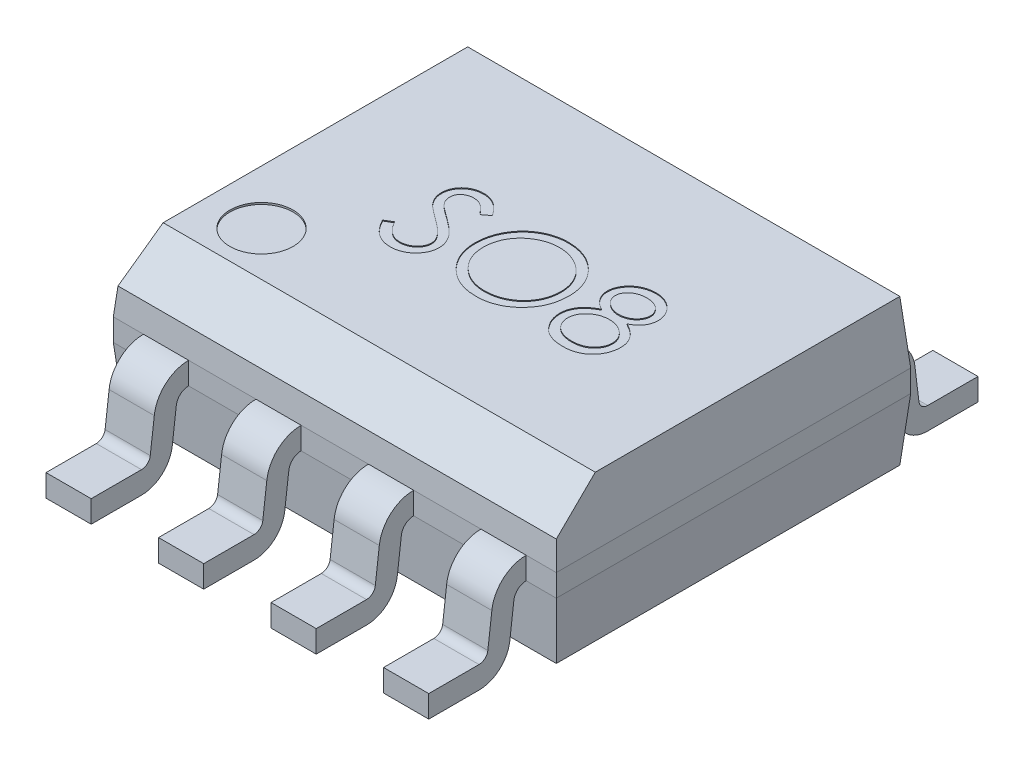
from build123d import *

# Parameters (mm, degrees)
SKETCH1_W                = 5
SKETCH1_H                = 4
BOSS_EXTRUDE1_DEPTH      = 0.125
BOSS_EXTRUDE1_DEPTH_BACK = 0.125
SKETCH2_W                = 5
SKETCH2_H                = 4
BOSS_EXTRUDE2_DEPTH      = 0.7
BOSS_EXTRUDE2_TAPER      = 5
SKETCH3_W                = 5
SKETCH3_H                = 4
BOSS_EXTRUDE3_DEPTH      = 0.7
BOSS_EXTRUDE3_TAPER      = 5
CHAMFER1_SIZE            = 0.4
CHAMFER1_SIZE2           = 0.440025147
BOSS_EXTRUDE4_START      = 0.38
BOSS_EXTRUDE4_DEPTH      = 0.51
LPATTERN1_COUNT          = 2
LPATTERN1_PITCH          = 1.27
LPATTERN1_COL_COUNT      = 3
LPATTERN1_COL_PITCH      = 1.27
SKETCH6_R                = 0.356697025
CUT_EXTRUDE1_DEPTH       = 0.02
CUT_EXTRUDE2_DEPTH       = 0.01


with BuildPart() as part:
    # Sketch1 → Boss-Extrude1 (new, two sides)
    with BuildSketch(Plane(origin=(0, 0.92, 0), x_dir=(1, 0, 0), z_dir=(0, 1, 0))) as boss_extrude1_sk:
        Rectangle(SKETCH1_W, SKETCH1_H)
    extrude(amount=BOSS_EXTRUDE1_DEPTH)
    extrude(boss_extrude1_sk.sketch, amount=-BOSS_EXTRUDE1_DEPTH_BACK)

    # Sketch2 → Boss-Extrude2 (add)
    with BuildSketch(Plane(origin=(0, 1.045, 0), x_dir=(1, 0, 0), z_dir=(0, 1, 0))):
        Rectangle(SKETCH2_W, SKETCH2_H)
    extrude(amount=BOSS_EXTRUDE2_DEPTH, taper=BOSS_EXTRUDE2_TAPER)

    # Sketch3 → Boss-Extrude3 (add)
    with BuildSketch(Plane.XZ.offset(-0.795)):
        Rectangle(SKETCH3_W, SKETCH3_H)
    extrude(amount=BOSS_EXTRUDE3_DEPTH, taper=BOSS_EXTRUDE3_TAPER)

    # Chamfer1
    chamfer1_edges = [part.edges().sort_by_distance(p)[0] for p in [
        (0, 1.745, 1.938757936),
    ]]
    chamfer1_side = [part.faces().sort_by_distance(p)[0] for p in [
        (0, 1.393553299, 1.969505538),
    ]]
    chamfer(chamfer1_edges, length=CHAMFER1_SIZE, length2=CHAMFER1_SIZE2, reference=chamfer1_side[0])

    # Sketch5 → Boss-Extrude4 (add)
    with BuildSketch(Plane(origin=(0, 0, 0), x_dir=(0, 0, -1), z_dir=(1, 0, 0)).offset(BOSS_EXTRUDE4_START)):
        with BuildLine():
            Line((2.43285762, 0.329963507), (2.38761047, 0.698105953))
            ThreePointArc((2.38761047, 0.698105953), (2.260085254, 0.945612561), (2, 1.045))
            Line((2, 1.045), (2, 0.795))
            ThreePointArc((2, 0.795), (2.091746463, 0.76074775), (2.138599743, 0.674751237))
            Line((2.138599743, 0.674751237), (2.184724748, 0.299466331))
            ThreePointArc((2.184724748, 0.299466331), (2.300209515, 0.080013931), (2.532110769, -0.007837622))
            Line((2.532110769, -0.007837622), (3.099630301, -0.007837622))
            Line((3.099630301, -0.007837622), (3.099630301, 0.242162378))
            Line((3.099630301, 0.242162378), (2.532110769, 0.242162378))
            ThreePointArc((2.532110769, 0.242162378), (2.465853268, 0.267262822), (2.43285762, 0.329963507))
        make_face()
        with BuildLine():
            ThreePointArc((-2.138599743, 0.674751237), (-2.091746463, 0.76074775), (-2, 0.795))
            Line((-2, 0.795), (-2, 1.045))
            ThreePointArc((-2, 1.045), (-2.260085254, 0.945612561), (-2.38761047, 0.698105953))
            Line((-2.38761047, 0.698105953), (-2.43285762, 0.329963507))
            ThreePointArc((-2.43285762, 0.329963507), (-2.465853268, 0.267262822), (-2.532110769, 0.242162378))
            Line((-2.532110769, 0.242162378), (-3.099630301, 0.242162378))
            Line((-3.099630301, 0.242162378), (-3.099630301, -0.007837622))
            Line((-3.099630301, -0.007837622), (-2.532110769, -0.007837622))
            ThreePointArc((-2.532110769, -0.007837622), (-2.300209515, 0.080013931), (-2.184724748, 0.299466331))
            Line((-2.184724748, 0.299466331), (-2.138599743, 0.674751237))
        make_face()
    boss_extrude4 = extrude(amount=BOSS_EXTRUDE4_DEPTH)

    # LPattern1: Boss-Extrude4 ×2
    with Locations(*[(i * LPATTERN1_PITCH, 0, 0) for i in range(1, LPATTERN1_COUNT)]):
        add(boss_extrude4)

    # LPattern1 col: Boss-Extrude4 ×3
    with Locations(*[(-i * LPATTERN1_COL_PITCH, 0, 0) for i in range(1, LPATTERN1_COL_COUNT)]):
        add(boss_extrude4)

    # Sketch6 → Cut-Extrude1 (cut)
    with BuildSketch(Plane(origin=(0, 1.745, 0), x_dir=(1, 0, 0), z_dir=(0, 1, 0))):
        with Locations(Location((-1.829466097, -0.997890598, 0), (0, 0, 270))):
            Circle(SKETCH6_R)
    extrude(amount=-CUT_EXTRUDE1_DEPTH, mode=Mode.SUBTRACT)

    # Sketch7 → Cut-Extrude2 (cut)
    with BuildSketch(Plane(origin=(0, 1.745, 0), x_dir=(1, 0, 0), z_dir=(0, 1, 0))):
        with BuildLine():
            Line((-1.226287299, -0.23455359), (-1.141752043, -0.1838725))
            add(Edge.make_bspline(
                [(-1.141752043, -0.1838725), (-1.133889689, -0.197033753), (-1.118825723, -0.222250206), (-1.093696763, -0.256323932), (-1.067658789, -0.285284548), (-1.040518979, -0.308963579), (-1.012442994, -0.327606118), (-0.98324755, -0.340806755), (-0.953031033, -0.349039891), (-0.932467084, -0.350039916), (-0.92220076, -0.350539167)],
                knots=[0, 0, 0, 0, 1.272034388, 2.437168799, 3.508375237, 4.49857839, 5.41946034, 6.295179144, 7.148887113, 8, 8, 8, 8], degree=3))
            add(Edge.make_bspline(
                [(-0.92220076, -0.350539167), (-0.913433086, -0.350294975), (-0.896051151, -0.349810863), (-0.870461939, -0.345159206), (-0.845609995, -0.338012883), (-0.822007527, -0.327778331), (-0.799980209, -0.315395907), (-0.78066401, -0.300439856), (-0.763965121, -0.283695226), (-0.750305374, -0.265014467), (-0.739825363, -0.244923854), (-0.731770487, -0.224302153), (-0.727300466, -0.202825419), (-0.726627108, -0.188365287), (-0.726287299, -0.181068013)],
                knots=[0, 0, 0, 0, 1.095163259, 2.171163733, 3.241058638, 4.321873601, 5.38011039, 6.391990106, 7.366004449, 8.327778327, 9.272591725, 10.192022065, 11.087607919, 12, 12, 12, 12], degree=3))
            add(Edge.make_bspline(
                [(-0.726287299, -0.181068013), (-0.726708531, -0.172742056), (-0.727564833, -0.155816602), (-0.734802399, -0.130845273), (-0.746187898, -0.10613311), (-0.75669151, -0.090847034), (-0.762144671, -0.082910962)],
                knots=[0, 0, 0, 0, 0.938893495, 1.908633276, 2.914225137, 4, 4, 4, 4], degree=3))
            add(Edge.make_bspline(
                [(-0.762144671, -0.082910962), (-0.766621989, -0.077183298), (-0.776021559, -0.065158784), (-0.792180848, -0.047260145), (-0.811142595, -0.02879774), (-0.832257897, -0.009066581), (-0.856295922, 0.011015647), (-0.882503783, 0.032406583), (-0.9115506, 0.054292748), (-0.931921885, 0.068970624), (-0.942433132, 0.076544166)],
                knots=[0, 0, 0, 0, 0.722233717, 1.516239348, 2.393582979, 3.351407094, 4.387010283, 5.505090956, 6.712668013, 8, 8, 8, 8], degree=3))
            add(Edge.make_bspline(
                [(-0.942433132, 0.076544166), (-0.952954274, 0.084038048), (-0.973069896, 0.098365781), (-1.001200919, 0.119629862), (-1.02635648, 0.139070967), (-1.048424771, 0.156872114), (-1.067396084, 0.173035715), (-1.083419916, 0.187406555), (-1.096088075, 0.200373286), (-1.103132527, 0.208785098), (-1.106295312, 0.212561794)],
                knots=[0, 0, 0, 0, 1.452282411, 2.77665338, 3.964542531, 5.026858415, 5.96415736, 6.766646006, 7.446254459, 8, 8, 8, 8], degree=3))
            add(Edge.make_bspline(
                [(-1.106295312, 0.212561794), (-1.110716039, 0.218447805), (-1.119409992, 0.230023435), (-1.130885994, 0.248116251), (-1.14064004, 0.266637184), (-1.148286421, 0.285636003), (-1.154725341, 0.304845982), (-1.159056178, 0.324517767), (-1.161768006, 0.344563086), (-1.162045716, 0.358052658), (-1.162184735, 0.364805384)],
                knots=[0, 0, 0, 0, 1.068054152, 2.10047183, 3.106115577, 4.101338837, 5.06977816, 6.043150881, 7.020423561, 8, 8, 8, 8], degree=3))
            add(Edge.make_bspline(
                [(-1.162184735, 0.364805384), (-1.161811818, 0.37538532), (-1.161073955, 0.396319052), (-1.154833807, 0.42689929), (-1.144984409, 0.456095409), (-1.13118587, 0.483618361), (-1.113398055, 0.508751499), (-1.092813491, 0.531783924), (-1.068295923, 0.551146376), (-1.041395174, 0.568064107), (-1.011950496, 0.581305799), (-0.981095952, 0.591294651), (-0.948782503, 0.596954439), (-0.926895893, 0.597766657), (-0.915790504, 0.598178782)],
                knots=[0, 0, 0, 0, 1.005424448, 1.989358655, 2.955360095, 3.929531133, 4.905563448, 5.876582895, 6.856512386, 7.866279853, 8.892233794, 9.918561126, 10.94386622, 12, 12, 12, 12], degree=3))
            add(Edge.make_bspline(
                [(-0.915790504, 0.598178782), (-0.904006475, 0.597772338), (-0.880571803, 0.596964052), (-0.846100599, 0.589936186), (-0.812911823, 0.578307423), (-0.786213747, 0.565110663), (-0.765318673, 0.551930259), (-0.749383606, 0.539924595), (-0.733235763, 0.526103135), (-0.71674489, 0.510429065), (-0.700190416, 0.492758565), (-0.683326573, 0.473212654), (-0.666113924, 0.45191078), (-0.655040821, 0.43670378), (-0.649364222, 0.428907948)],
                knots=[0, 0, 0, 0, 1.286793592, 2.559021753, 3.825965368, 5.121522368, 5.803751409, 6.523245864, 7.299691795, 8.125521123, 9.008227632, 9.944561021, 10.946284179, 12, 12, 12, 12], degree=3))
            Line((-0.649364222, 0.428907948), (-0.73049403, 0.367409551))
            add(Edge.make_bspline(
                [(-0.73049403, 0.367409551), (-0.735392868, 0.373720605), (-0.744826884, 0.38587422), (-0.759149594, 0.402894596), (-0.772649208, 0.418442162), (-0.785949322, 0.431946484), (-0.798347503, 0.444147094), (-0.810380943, 0.454592739), (-0.821876472, 0.463385766), (-0.836367018, 0.47276964), (-0.854572081, 0.482071498), (-0.877424805, 0.489942663), (-0.901306598, 0.494672681), (-0.917572207, 0.495298078), (-0.92580653, 0.495614679)],
                knots=[0, 0, 0, 0, 1.181633172, 2.275549214, 3.290209073, 4.226197932, 5.078386478, 5.862611352, 6.581680152, 7.217281963, 8.414376989, 9.595101626, 10.782541182, 12, 12, 12, 12], degree=3))
            add(Edge.make_bspline(
                [(-0.92580653, 0.495614679), (-0.936136965, 0.495268479), (-0.956058235, 0.494600865), (-0.98434116, 0.487309441), (-1.009796567, 0.475828909), (-1.031668729, 0.459738915), (-1.049879293, 0.440675775), (-1.063052282, 0.418738959), (-1.0709809, 0.394515415), (-1.071948409, 0.377617799), (-1.072441145, 0.369012115)],
                knots=[0, 0, 0, 0, 1.14458467, 2.207223713, 3.21896685, 4.227309161, 5.202851033, 6.127160689, 7.046193047, 8, 8, 8, 8], degree=3))
            add(Edge.make_bspline(
                [(-1.072441145, 0.369012115), (-1.072328823, 0.36365455), (-1.072103996, 0.352930658), (-1.068968339, 0.337087395), (-1.06493996, 0.321284155), (-1.05855635, 0.305591989), (-1.049743407, 0.289736457), (-1.038170499, 0.273444532), (-1.023595267, 0.256572616), (-1.012430406, 0.24559908), (-1.006535696, 0.239805384)],
                knots=[0, 0, 0, 0, 0.858281714, 1.717966888, 2.583508476, 3.4729293, 4.427298488, 5.488583878, 6.674047936, 8, 8, 8, 8], degree=3))
            add(Edge.make_bspline(
                [(-1.006535696, 0.239805384), (-1.004346733, 0.237851948), (-0.999146256, 0.233211032), (-0.989638849, 0.225613237), (-0.977083764, 0.216241016), (-0.961808849, 0.20464464), (-0.94353246, 0.191192794), (-0.922252587, 0.176057476), (-0.898206435, 0.158747345), (-0.88114303, 0.146645191), (-0.872120632, 0.140246089)],
                knots=[0, 0, 0, 0, 0.420754252, 0.999615792, 1.744751191, 2.668019286, 3.750313428, 4.999500688, 6.413464383, 8, 8, 8, 8], degree=3))
            add(Edge.make_bspline(
                [(-0.872120632, 0.140246089), (-0.861267514, 0.132348558), (-0.840251955, 0.117056083), (-0.81034979, 0.094080175), (-0.783237273, 0.071609384), (-0.758819215, 0.04978721), (-0.736854384, 0.028779184), (-0.717586464, 0.008332561), (-0.700819126, -0.011406174), (-0.682767921, -0.036712625), (-0.66432283, -0.067792934), (-0.648482399, -0.105872431), (-0.6384943, -0.144099951), (-0.637188153, -0.169793333), (-0.636543709, -0.182470257)],
                knots=[0, 0, 0, 0, 1.163667725, 2.253281268, 3.268753668, 4.215851969, 5.092017293, 5.902905408, 6.650798638, 7.335211899, 8.59617414, 9.77448103, 10.901945474, 12, 12, 12, 12], degree=3))
            add(Edge.make_bspline(
                [(-0.636543709, -0.182470257), (-0.636731463, -0.191435504), (-0.637103324, -0.209191899), (-0.641377871, -0.235264778), (-0.647640633, -0.260587884), (-0.657079842, -0.284848202), (-0.668600745, -0.308489563), (-0.683219673, -0.33089182), (-0.700164725, -0.352550791), (-0.719602944, -0.372888931), (-0.740873202, -0.391559273), (-0.763354257, -0.408167576), (-0.787082907, -0.422015669), (-0.811930426, -0.433315909), (-0.837902522, -0.442154057), (-0.86499046, -0.448557734), (-0.893238892, -0.452487937), (-0.91243903, -0.452895869), (-0.92220076, -0.45310327)],
                knots=[0, 0, 0, 0, 0.983748083, 1.948392443, 2.894712957, 3.844097841, 4.80183111, 5.778335162, 6.776009319, 7.81870978, 8.863265674, 9.881300176, 10.883814829, 11.87499822, 12.874611388, 13.892143829, 14.928324115, 16, 16, 16, 16], degree=3))
            add(Edge.make_bspline(
                [(-0.92220076, -0.45310327), (-0.929753716, -0.452957218), (-0.944764504, -0.452666953), (-0.966967213, -0.450100873), (-0.988721382, -0.446470272), (-1.009754034, -0.440706252), (-1.030336151, -0.43371283), (-1.050378218, -0.425101878), (-1.069889948, -0.414782678), (-1.088980686, -0.402984099), (-1.107601879, -0.389253315), (-1.125578869, -0.373260887), (-1.143501494, -0.355447886), (-1.16084075, -0.335330582), (-1.177947363, -0.313233987), (-1.194484051, -0.288951363), (-1.210793113, -0.262614976), (-1.221026104, -0.244082095), (-1.226287299, -0.23455359)],
                knots=[0, 0, 0, 0, 0.915332311, 1.819136955, 2.706846663, 3.586547465, 4.459518054, 5.340707479, 6.227863349, 7.133153174, 8.059268498, 9.028702269, 10.047606654, 11.120612155, 12.245963614, 13.433783089, 14.680604001, 16, 16, 16, 16], degree=3))
        make_face()
        with BuildLine():
            add(Edge.make_bspline(
                [(0.036533214, 0.598178782), (0.055049816, 0.597709788), (0.091417949, 0.596788644), (0.14486792, 0.589737472), (0.19589509, 0.577538789), (0.24491513, 0.561292223), (0.291341694, 0.539619541), (0.335524235, 0.513423784), (0.377357627, 0.482430511), (0.416278022, 0.446879303), (0.451894294, 0.408198316), (0.483273118, 0.366918913), (0.509570917, 0.323290684), (0.531166856, 0.277444732), (0.548109316, 0.229484741), (0.559800471, 0.179155026), (0.567268514, 0.126781686), (0.568141593, 0.091059725), (0.568584496, 0.072938397)],
                knots=[0, 0, 0, 0, 1.065120563, 2.091984664, 3.0946048, 4.079830382, 5.057816894, 6.036188127, 7.030412546, 8.04752943, 9.064399622, 10.05169764, 11.02544977, 11.989514704, 12.962713494, 13.945757189, 14.957906945, 16, 16, 16, 16], degree=3))
            add(Edge.make_bspline(
                [(0.568584496, 0.072938397), (0.568141658, 0.054950555), (0.567268773, 0.019494435), (0.55979198, -0.032546549), (0.54806598, -0.082572462), (0.531324189, -0.130499792), (0.509831196, -0.176379096), (0.48335829, -0.220089654), (0.452175086, -0.261645796), (0.416687415, -0.300592272), (0.378001403, -0.336305835), (0.336507041, -0.367425514), (0.293137521, -0.394203835), (0.247334747, -0.415570599), (0.199706165, -0.432648291), (0.149825501, -0.444291899), (0.097926486, -0.451802483), (0.062534771, -0.452664916), (0.044546034, -0.45310327)],
                knots=[0, 0, 0, 0, 1.043624062, 2.057103931, 3.04512605, 4.022047818, 4.998200453, 5.980619268, 6.982898556, 8.009068085, 9.034988726, 10.034168286, 11.015286542, 11.987931943, 12.962482838, 13.94673481, 14.956375938, 16, 16, 16, 16], degree=3))
            add(Edge.make_bspline(
                [(0.044546034, -0.45310327), (0.0264248, -0.452660588), (-0.009296976, -0.451787944), (-0.061736129, -0.444307542), (-0.112101198, -0.432610027), (-0.160248156, -0.415893045), (-0.20620385, -0.394288122), (-0.250058159, -0.367944014), (-0.291635058, -0.336684831), (-0.330589843, -0.301208666), (-0.366232471, -0.262588223), (-0.397306579, -0.221207007), (-0.423656611, -0.177876877), (-0.445188992, -0.132477584), (-0.46223598, -0.085228601), (-0.473865928, -0.03581475), (-0.481390486, 0.015482252), (-0.482257585, 0.050408794), (-0.482697555, 0.068130705)],
                knots=[0, 0, 0, 0, 1.053102029, 2.075944431, 3.073151272, 4.055350789, 5.033113405, 6.020478099, 7.024410459, 8.052272461, 9.079885166, 10.07527673, 11.055994387, 12.023226415, 12.992069828, 13.970394897, 14.97016774, 16, 16, 16, 16], degree=3))
            add(Edge.make_bspline(
                [(-0.482697555, 0.068130705), (-0.482544802, 0.080025753), (-0.482241223, 0.103665788), (-0.478586454, 0.138770531), (-0.473283111, 0.173310719), (-0.465682564, 0.207188133), (-0.455742088, 0.240319843), (-0.444012937, 0.272934346), (-0.429687267, 0.304701125), (-0.413492797, 0.335770665), (-0.395417994, 0.365658638), (-0.375453494, 0.393909948), (-0.354300532, 0.420761661), (-0.331110991, 0.445517948), (-0.306649149, 0.468898993), (-0.280518184, 0.490545483), (-0.252877543, 0.510652612), (-0.223608292, 0.528772709), (-0.193431642, 0.545161034), (-0.162323991, 0.55922442), (-0.130707828, 0.571294723), (-0.098435071, 0.581077816), (-0.065591422, 0.588801255), (-0.032105198, 0.594060499), (0.001996924, 0.597724589), (0.024971587, 0.598026733), (0.036533214, 0.598178782)],
                knots=[0, 0, 0, 0, 1.037015668, 2.060948919, 3.074880161, 4.083647147, 5.086022904, 6.090072063, 7.104153813, 8.122640571, 9.144368836, 10.147691507, 11.138137339, 12.123020368, 13.103399296, 14.087645067, 15.080126199, 16.082011238, 17.087798457, 18.072939717, 19.057185487, 20.037253025, 21.01195951, 21.997135196, 22.992090687, 24, 24, 24, 24], degree=3))
        make_face()
        with BuildLine():
            add(Edge.make_bspline(
                [(0.040940265, 0.495614679), (0.03145037, 0.495498996), (0.012561303, 0.495268736), (-0.015519993, 0.492235675), (-0.043231974, 0.487912849), (-0.070580363, 0.4817467), (-0.097450731, 0.473345542), (-0.124093543, 0.463676712), (-0.150265844, 0.451899257), (-0.175881232, 0.43859277), (-0.200714111, 0.423864507), (-0.224146311, 0.407586859), (-0.246238495, 0.390141558), (-0.266936571, 0.37148789), (-0.286179764, 0.351530861), (-0.304346821, 0.330573022), (-0.320709559, 0.308015339), (-0.335705438, 0.284469509), (-0.349124821, 0.2599662), (-0.361057779, 0.234763382), (-0.370818925, 0.208655471), (-0.378779604, 0.181925712), (-0.385379549, 0.154616438), (-0.389560671, 0.126520481), (-0.392627059, 0.097779021), (-0.392844158, 0.078355634), (-0.392953966, 0.068531346)],
                knots=[0, 0, 0, 0, 1.008559885, 2.007477868, 2.99961109, 3.989939068, 4.984837346, 5.991145699, 7.001802488, 8.033829008, 9.059044045, 10.069351652, 11.065060232, 12.050310815, 13.029377138, 14.011219647, 14.996725999, 15.989392538, 16.977580475, 17.965360261, 18.951710183, 19.937753436, 20.929683414, 21.935841486, 22.955955122, 24, 24, 24, 24], degree=3))
            add(Edge.make_bspline(
                [(-0.392953966, 0.068531346), (-0.392589719, 0.054084997), (-0.391873134, 0.02566456), (-0.385599543, -0.015983481), (-0.375936121, -0.056008706), (-0.36169116, -0.094192109), (-0.343876698, -0.130861904), (-0.321869015, -0.165692791), (-0.295794991, -0.198694184), (-0.26617684, -0.229635689), (-0.233798924, -0.257877347), (-0.199418144, -0.282666893), (-0.163402828, -0.30364125), (-0.125659056, -0.320728413), (-0.08638833, -0.334268338), (-0.045337601, -0.343547947), (-0.002780327, -0.34965522), (0.026228431, -0.350241722), (0.040940265, -0.350539167)],
                knots=[0, 0, 0, 0, 1.032063989, 2.030389145, 3.003944642, 3.970395727, 4.937377036, 5.913328081, 6.909231446, 7.93887556, 8.970685674, 9.976071282, 10.964166581, 11.944589148, 12.933237628, 13.927779006, 14.949070134, 16, 16, 16, 16], degree=3))
            add(Edge.make_bspline(
                [(0.040940265, -0.350539167), (0.050828694, -0.350403309), (0.070440419, -0.350133861), (0.099610568, -0.347419953), (0.1282552, -0.34306799), (0.156334137, -0.336802089), (0.183815512, -0.32896003), (0.210814027, -0.319643536), (0.23704211, -0.308020335), (0.262830635, -0.295178063), (0.287515276, -0.280538018), (0.311079713, -0.264812832), (0.332929993, -0.247393227), (0.353612585, -0.229016709), (0.372934782, -0.209312752), (0.39076592, -0.188306975), (0.407045958, -0.165866787), (0.422036143, -0.142356671), (0.435408504, -0.117786313), (0.447059675, -0.092492119), (0.456944279, -0.066536374), (0.464923852, -0.039881639), (0.471176841, -0.012578539), (0.47548539, 0.015409483), (0.478499229, 0.044026438), (0.478726394, 0.063381825), (0.478840906, 0.073138718)],
                knots=[0, 0, 0, 0, 1.047197238, 2.076906641, 3.100256066, 4.114471768, 5.12198147, 6.126382909, 7.136867548, 8.15857795, 9.17633901, 10.174870724, 11.156907918, 12.133735059, 13.104061851, 14.077631395, 15.04955518, 16.038496417, 17.029181396, 18.010275684, 18.986308667, 19.968651475, 20.955262928, 21.950658345, 22.966943676, 24, 24, 24, 24], degree=3))
            add(Edge.make_bspline(
                [(0.478840906, 0.073138718), (0.478726302, 0.082828862), (0.478498965, 0.102051047), (0.475486829, 0.130468424), (0.471172289, 0.158255056), (0.464954373, 0.185301857), (0.456940043, 0.211615721), (0.447057949, 0.237171935), (0.435405006, 0.262065705), (0.422031227, 0.286235504), (0.406998135, 0.309428286), (0.390571208, 0.331600404), (0.372466823, 0.352335473), (0.353202245, 0.372145386), (0.332296277, 0.39060764), (0.309843622, 0.40772836), (0.286116857, 0.423920724), (0.26099479, 0.438528027), (0.235067946, 0.452017808), (0.208463958, 0.463575238), (0.181484215, 0.473395843), (0.154197326, 0.481772119), (0.126373618, 0.487888699), (0.098201095, 0.49223957), (0.069718736, 0.495267681), (0.05056353, 0.495498646), (0.040940265, 0.495614679)],
                knots=[0, 0, 0, 0, 1.02996197, 2.043119294, 3.035359645, 4.018872909, 4.991431989, 5.957985074, 6.929999688, 7.912076566, 8.892894881, 9.867085534, 10.843653904, 11.817741046, 12.803660682, 13.806313499, 14.818574707, 15.856120519, 16.894564902, 17.924820532, 18.937903209, 19.946497019, 20.957711757, 21.963978472, 22.977135795, 24, 24, 24, 24], degree=3))
        make_face(mode=Mode.SUBTRACT)
        with BuildLine():
            add(Edge.make_bspline(
                [(1.170146996, 0.129629102), (1.178332295, 0.125361115), (1.194296362, 0.117037114), (1.217032707, 0.10363402), (1.237811279, 0.08950803), (1.257208583, 0.075326356), (1.274883826, 0.060545884), (1.290639372, 0.04510784), (1.304864406, 0.02939757), (1.317272059, 0.013149044), (1.328185441, -0.00359457), (1.33761748, -0.02087722), (1.345679537, -0.038661029), (1.352068949, -0.057140123), (1.357332318, -0.076043055), (1.360953919, -0.095613907), (1.36290161, -0.115723719), (1.363269842, -0.129314662), (1.363456291, -0.136196218)],
                knots=[0, 0, 0, 0, 1.272397273, 2.481599622, 3.635517121, 4.734568067, 5.792894095, 6.808321871, 7.773003508, 8.711915296, 9.623354172, 10.525449501, 11.423591555, 12.311487226, 13.218079475, 14.126165749, 15.051214107, 16, 16, 16, 16], degree=3))
            add(Edge.make_bspline(
                [(1.363456291, -0.136196218), (1.363235885, -0.145824142), (1.362799619, -0.164881415), (1.358999624, -0.193008876), (1.353310201, -0.220326528), (1.345001769, -0.246828382), (1.334226515, -0.272368203), (1.320947419, -0.296967853), (1.305915646, -0.321030513), (1.293843577, -0.335836056), (1.287735137, -0.343327629)],
                knots=[0, 0, 0, 0, 1.025265484, 2.029385089, 3.018602448, 3.995076438, 4.983346944, 5.966715145, 6.97116228, 8, 8, 8, 8], degree=3))
            add(Edge.make_bspline(
                [(1.287735137, -0.343327629), (1.279781859, -0.352068707), (1.263973583, -0.369442848), (1.236892746, -0.392000222), (1.207172208, -0.410957192), (1.17492697, -0.426406304), (1.140243227, -0.438430836), (1.103128368, -0.447071555), (1.063510039, -0.45202082), (1.036279904, -0.452736246), (1.022310457, -0.45310327)],
                knots=[0, 0, 0, 0, 0.954267603, 1.896743057, 2.838368354, 3.796610408, 4.779680527, 5.799409237, 6.871065594, 8, 8, 8, 8], degree=3))
            add(Edge.make_bspline(
                [(1.022310457, -0.45310327), (1.008878061, -0.45277399), (0.982739981, -0.452133246), (0.944694873, -0.44779198), (0.909231139, -0.440184018), (0.876142577, -0.429771272), (0.845628664, -0.416225493), (0.81777635, -0.399365947), (0.792183786, -0.37987125), (0.769627651, -0.357181513), (0.749602381, -0.332879264), (0.732011509, -0.307807375), (0.717390343, -0.281963559), (0.705011173, -0.255733168), (0.695534595, -0.228748553), (0.688971107, -0.201148549), (0.684802731, -0.172981365), (0.684248121, -0.153972322), (0.683969111, -0.144409359)],
                knots=[0, 0, 0, 0, 1.256902934, 2.445805442, 3.576955095, 4.645999104, 5.686449165, 6.692658513, 7.68621702, 8.689161843, 9.678783111, 10.630372946, 11.551080876, 12.453998257, 13.34127905, 14.221779781, 15.105423033, 16, 16, 16, 16], degree=3))
            add(Edge.make_bspline(
                [(0.683969111, -0.144409359), (0.68413422, -0.137392447), (0.684460534, -0.123524553), (0.686719062, -0.103036173), (0.690350051, -0.08309442), (0.695281324, -0.063625636), (0.701964474, -0.044771558), (0.710033655, -0.026442852), (0.719442785, -0.008618823), (0.730323117, 0.008798), (0.742980839, 0.025563575), (0.75731331, 0.04196243), (0.773606987, 0.057740107), (0.791680604, 0.073089371), (0.811327615, 0.088282506), (0.833058338, 0.102498429), (0.8562967, 0.116743561), (0.87281253, 0.125260226), (0.881284816, 0.129629102)],
                knots=[0, 0, 0, 0, 0.941657376, 1.861047343, 2.762797495, 3.66048619, 4.553285746, 5.444104102, 6.34607688, 7.256116206, 8.197091036, 9.162375105, 10.176350973, 11.237807142, 12.343728897, 13.50695164, 14.721116704, 16, 16, 16, 16], degree=3))
            add(Edge.make_bspline(
                [(0.881284816, 0.129629102), (0.869687281, 0.135953322), (0.847231206, 0.148198781), (0.81749708, 0.170697869), (0.791956902, 0.195065816), (0.771312697, 0.221817186), (0.755063489, 0.250116293), (0.743915316, 0.279786079), (0.736373463, 0.310276397), (0.73562637, 0.331106739), (0.735251163, 0.341568205)],
                knots=[0, 0, 0, 0, 1.166880483, 2.259407225, 3.286803203, 4.280235371, 5.237608625, 6.161067461, 7.076446754, 8, 8, 8, 8], degree=3))
            add(Edge.make_bspline(
                [(0.735251163, 0.341568205), (0.735718427, 0.35222465), (0.736657709, 0.373645963), (0.744252943, 0.405533427), (0.756630105, 0.436852446), (0.773464676, 0.467451221), (0.794432452, 0.496294139), (0.819588608, 0.522162981), (0.848332407, 0.544823405), (0.880520369, 0.563845168), (0.915159293, 0.579326214), (0.951706643, 0.590005763), (0.989525641, 0.596987511), (1.015267847, 0.597777983), (1.028320073, 0.598178782)],
                knots=[0, 0, 0, 0, 0.888701115, 1.786444228, 2.72001202, 3.692817113, 4.693886446, 5.687152267, 6.695133018, 7.739871481, 8.800368666, 9.853104506, 10.91144658, 12, 12, 12, 12], degree=3))
            add(Edge.make_bspline(
                [(1.028320073, 0.598178782), (1.041035449, 0.597765541), (1.066108721, 0.596950677), (1.102964329, 0.590154426), (1.138228579, 0.578803135), (1.171779865, 0.563403928), (1.203017541, 0.544436231), (1.230618201, 0.521464552), (1.254998939, 0.495709823), (1.275165909, 0.466875651), (1.291783877, 0.436394453), (1.303355563, 0.404502304), (1.310770413, 0.371888287), (1.31170566, 0.349820286), (1.31217424, 0.338763718)],
                knots=[0, 0, 0, 0, 1.072916533, 2.115669174, 3.151510826, 4.193348718, 5.225979165, 6.227137561, 7.216255879, 8.211077061, 9.189680878, 10.138522389, 11.067357538, 12, 12, 12, 12], degree=3))
            add(Edge.make_bspline(
                [(1.31217424, 0.338763718), (1.311764365, 0.327913242), (1.310959395, 0.306603525), (1.304187984, 0.275538805), (1.29278418, 0.246446794), (1.277214419, 0.218997379), (1.256921422, 0.19368838), (1.23217607, 0.17019796), (1.203175648, 0.148333152), (1.181386823, 0.13599419), (1.170146996, 0.129629102)],
                knots=[0, 0, 0, 0, 0.975232327, 1.915300861, 2.843280834, 3.77672583, 4.742871857, 5.749627742, 6.839139064, 8, 8, 8, 8], degree=3))
        make_face()
        with BuildLine():
            add(Edge.make_bspline(
                [(1.02331206, 0.495614679), (1.016297544, 0.495428553), (1.002574084, 0.49506441), (0.982451606, 0.493161942), (0.963316644, 0.489461023), (0.944969273, 0.484535677), (0.927661041, 0.477881966), (0.911156882, 0.47005482), (0.895737685, 0.460538802), (0.881217313, 0.449864174), (0.868145663, 0.438123343), (0.856544362, 0.425890852), (0.846907758, 0.412926454), (0.838724584, 0.399552637), (0.832787008, 0.385372473), (0.828340064, 0.370820708), (0.825333952, 0.355713455), (0.825108698, 0.345388738), (0.824994752, 0.340165961)],
                knots=[0, 0, 0, 0, 1.203892937, 2.355340988, 3.463153438, 4.544400666, 5.610487187, 6.640501085, 7.674077295, 8.714426146, 9.728707835, 10.68524104, 11.601827946, 12.495867327, 13.368432065, 14.231010473, 15.105153427, 16, 16, 16, 16], degree=3))
            add(Edge.make_bspline(
                [(0.824994752, 0.340165961), (0.825191143, 0.334942958), (0.825579239, 0.324621555), (0.828580704, 0.309379879), (0.833054091, 0.294402268), (0.840097137, 0.280044865), (0.848544668, 0.26580962), (0.858970804, 0.252052309), (0.871396241, 0.238725056), (0.885404081, 0.225941216), (0.90066452, 0.213970141), (0.91683139, 0.203577803), (0.933701787, 0.194882343), (0.951102378, 0.18764537), (0.969210506, 0.182019674), (0.987915213, 0.178028632), (1.007219642, 0.175548062), (1.020299808, 0.17525177), (1.026917829, 0.175101859)],
                knots=[0, 0, 0, 0, 0.873023192, 1.725219244, 2.590779336, 3.480155217, 4.391973325, 5.357036234, 6.360879153, 7.436073238, 8.526419356, 9.601555421, 10.645666583, 11.697338044, 12.750135903, 13.812665442, 14.89329948, 16, 16, 16, 16], degree=3))
            add(Edge.make_bspline(
                [(1.026917829, 0.175101859), (1.035417859, 0.175351249), (1.052333964, 0.175847567), (1.077270916, 0.180462188), (1.101517386, 0.187721022), (1.124814216, 0.197652441), (1.146558383, 0.210117544), (1.165941259, 0.225041263), (1.182797514, 0.242079005), (1.196951975, 0.26096553), (1.207926216, 0.281065983), (1.21646959, 0.301237496), (1.221458509, 0.321695276), (1.222109242, 0.335400123), (1.22243065, 0.342169166)],
                knots=[0, 0, 0, 0, 1.076279235, 2.141928126, 3.20205304, 4.278698113, 5.344010996, 6.36967002, 7.368914609, 8.37248503, 9.349703398, 10.264243087, 11.142681841, 12, 12, 12, 12], degree=3))
            add(Edge.make_bspline(
                [(1.22243065, 0.342169166), (1.222278679, 0.346920034), (1.221977039, 0.356349825), (1.219491309, 0.370275072), (1.215383928, 0.383883524), (1.209823048, 0.397287602), (1.202505964, 0.410299239), (1.193830481, 0.423122979), (1.183292052, 0.43547034), (1.1714645, 0.447629068), (1.158051526, 0.458881646), (1.14307898, 0.468777278), (1.126623623, 0.477180808), (1.108685065, 0.484006167), (1.089329373, 0.489132552), (1.068645694, 0.492971509), (1.046461567, 0.495135255), (1.031195924, 0.495451405), (1.02331206, 0.495614679)],
                knots=[0, 0, 0, 0, 0.814439003, 1.616544685, 2.417341072, 3.248991801, 4.09997495, 4.973547432, 5.9003056, 6.880240646, 7.880314356, 8.896779544, 9.951930927, 11.043077905, 12.18215768, 13.381699519, 14.647792085, 16, 16, 16, 16], degree=3))
        make_face(mode=Mode.SUBTRACT)
        with BuildLine():
            add(Edge.make_bspline(
                [(1.029121355, 0.072537756), (1.020228273, 0.072379573), (1.002782217, 0.072069256), (0.977223095, 0.068615113), (0.952693619, 0.063806715), (0.929276494, 0.05651219), (0.90698161, 0.047027478), (0.885688272, 0.035617609), (0.865559377, 0.02213034), (0.846872884, 0.006737021), (0.829809076, -0.009851394), (0.814838133, -0.027412004), (0.802124556, -0.045618442), (0.791886484, -0.064701936), (0.783483132, -0.084258396), (0.777964881, -0.104774852), (0.774427249, -0.125856885), (0.773952212, -0.140188341), (0.773712701, -0.147414167)],
                knots=[0, 0, 0, 0, 1.140299081, 2.23698856, 3.303958914, 4.344563908, 5.37730929, 6.408454204, 7.439741482, 8.480804886, 9.510774543, 10.48932336, 11.43758569, 12.353841022, 13.263987381, 14.161954604, 15.073269652, 16, 16, 16, 16], degree=3))
            add(Edge.make_bspline(
                [(0.773712701, -0.147414167), (0.774102204, -0.156394426), (0.774874967, -0.17421105), (0.781005436, -0.200543356), (0.79084416, -0.226035086), (0.80456565, -0.250478501), (0.821556385, -0.273321388), (0.842449662, -0.293232467), (0.865947044, -0.310924318), (0.892843574, -0.325233042), (0.922223136, -0.336660143), (0.954077915, -0.344533276), (0.987950749, -0.349745118), (1.011339204, -0.350270313), (1.02331206, -0.350539167)],
                knots=[0, 0, 0, 0, 0.898778495, 1.783155532, 2.693654817, 3.627872908, 4.583023416, 5.533784346, 6.509005473, 7.520592997, 8.575161974, 9.658835044, 10.801527049, 12, 12, 12, 12], degree=3))
            add(Edge.make_bspline(
                [(1.02331206, -0.350539167), (1.032669308, -0.350359508), (1.050900228, -0.350009473), (1.077496213, -0.346919675), (1.102594656, -0.342019782), (1.126146884, -0.334893055), (1.148416552, -0.326193061), (1.169026082, -0.315001038), (1.188505661, -0.302271803), (1.20589541, -0.287169472), (1.22173347, -0.271032474), (1.235542982, -0.253949604), (1.247530854, -0.236385138), (1.256939699, -0.217942142), (1.264461485, -0.198974453), (1.269868215, -0.179307164), (1.273204277, -0.158879954), (1.273541676, -0.145023077), (1.273712701, -0.137999103)],
                knots=[0, 0, 0, 0, 1.224942928, 2.386581632, 3.501229538, 4.569074225, 5.605009692, 6.626002462, 7.634866581, 8.645888296, 9.63523824, 10.59253846, 11.518950513, 12.414518923, 13.29783783, 14.186679152, 15.080837789, 16, 16, 16, 16], degree=3))
            add(Edge.make_bspline(
                [(1.273712701, -0.137999103), (1.273453887, -0.131177006), (1.272943551, -0.117725021), (1.269704497, -0.097791728), (1.264014246, -0.078533781), (1.256206419, -0.059719494), (1.245811858, -0.041730079), (1.233570466, -0.024096888), (1.218800718, -0.007309332), (1.202111405, 0.008762981), (1.18392313, 0.02362462), (1.16458966, 0.036771603), (1.144259814, 0.047843636), (1.122976611, 0.056848349), (1.100787309, 0.063930483), (1.07770823, 0.06887791), (1.053712351, 0.071992083), (1.03741096, 0.07235381), (1.029121355, 0.072537756)],
                knots=[0, 0, 0, 0, 0.917430815, 1.809013306, 2.70690318, 3.612392954, 4.541220862, 5.495268465, 6.494511384, 7.542276156, 8.608045339, 9.649016899, 10.681629292, 11.715607085, 12.752076957, 13.808767841, 14.885711793, 16, 16, 16, 16], degree=3))
        make_face(mode=Mode.SUBTRACT)
    extrude(amount=-CUT_EXTRUDE2_DEPTH, mode=Mode.SUBTRACT)


solid = part.part
